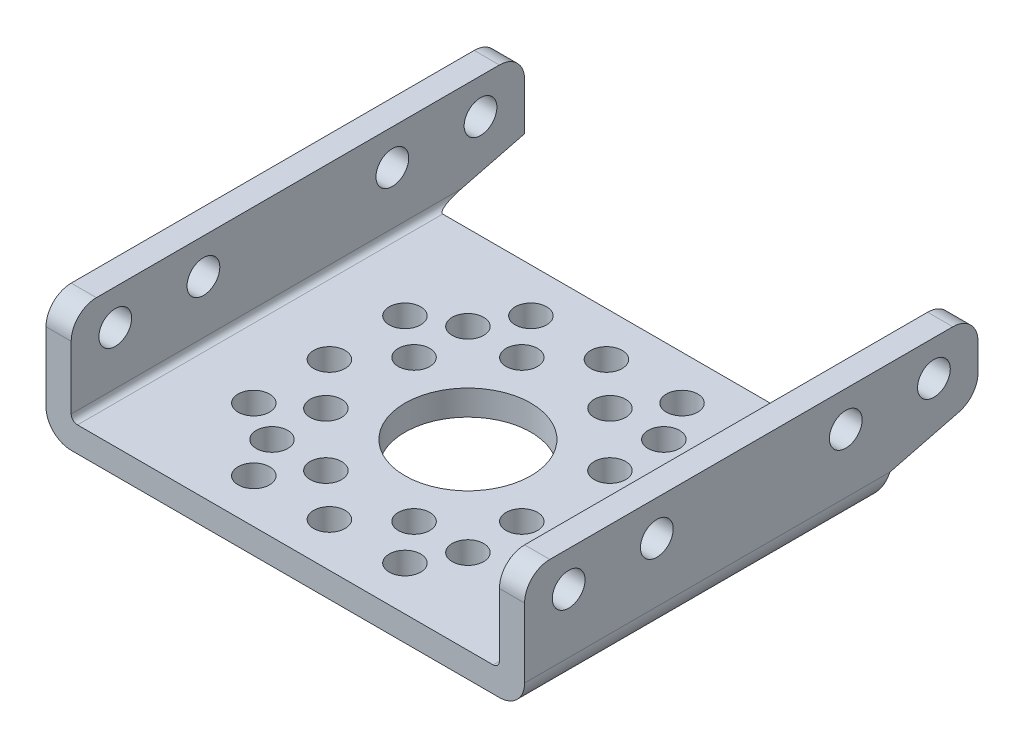
from build123d import *

# Parameters (mm, degrees)
SKETCH_1_W               = 38
SKETCH_1_H               = 29
EXTRUDE_1_DEPTH          = 2
SKETCH_2_W               = 2
SKETCH_2_H               = 36
EXTRUDE_2_DEPTH          = 7.5
SKETCH_3_R               = 5
SKETCH_3_R_2             = 1.25
CUT_EXTRUDE_1_DEPTH      = 8.5
CUT_EXTRUDE_1_DEPTH_BACK = 3
SKETCH_4_R               = 1.3
CUT_EXTRUDE_2_DEPTH      = 39
CUT_EXTRUDE_3_DEPTH      = 39
FILLET_1_R               = 2
FILLET_3_R               = 0.5
FILLET_4_R               = 2


with BuildPart() as part:
    # 스케치1 → 보스-돌출1 (new body)
    with BuildSketch(Plane(origin=(0, 0, 0), x_dir=(1, 0, 0), z_dir=(0, 1, 0))):
        with Locations((19, 14.5)):
            Rectangle(SKETCH_1_W, SKETCH_1_H)
    extrude(amount=EXTRUDE_1_DEPTH)

    # 스케치2 → 보스-돌출2 (add)
    with BuildSketch(Plane(origin=(0, 2, 0), x_dir=(1, 0, 0), z_dir=(0, 1, 0))):
        with Locations((1, 18)):
            Rectangle(SKETCH_2_W, SKETCH_2_H)
        with Locations((37, 18)):
            Rectangle(SKETCH_2_W, SKETCH_2_H)
    extrude(amount=EXTRUDE_2_DEPTH)

    # 스케치3 → 컷-돌출1 (cut, two sides)
    with BuildSketch(Plane(origin=(0, 2, 0), x_dir=(1, 0, 0), z_dir=(0, 1, 0))) as cut_extrude_1_sk:
        with Locations((19, 14.5)):
            Circle(SKETCH_3_R)
        with Locations((19, 25.5)):
            Circle(SKETCH_3_R_2)
        with Locations((26.778174593, 22.278174593)):
            Circle(SKETCH_3_R_2)
        with Locations((30, 14.5)):
            Circle(SKETCH_3_R_2)
        with Locations((26.778174593, 6.721825407)):
            Circle(SKETCH_3_R_2)
        with Locations((19, 3.5)):
            Circle(SKETCH_3_R_2)
        with Locations((11.221825407, 6.721825407)):
            Circle(SKETCH_3_R_2)
        with Locations((8, 14.5)):
            Circle(SKETCH_3_R_2)
        with Locations((11.221825407, 22.278174593)):
            Circle(SKETCH_3_R_2)
        with Locations((13, 25.5)):
            Circle(SKETCH_3_R_2)
        with Locations((25, 25.5)):
            Circle(SKETCH_3_R_2)
        with Locations((30, 20.5)):
            Circle(SKETCH_3_R_2)
        with Locations((30, 8.5)):
            Circle(SKETCH_3_R_2)
        with Locations((25, 3.5)):
            Circle(SKETCH_3_R_2)
        with Locations((13, 3.5)):
            Circle(SKETCH_3_R_2)
        with Locations((8, 8.5)):
            Circle(SKETCH_3_R_2)
        with Locations((8, 20.5)):
            Circle(SKETCH_3_R_2)
        with Locations((15.5, 22.278174593)):
            Circle(SKETCH_3_R_2)
        with Locations((22.5, 22.278174593)):
            Circle(SKETCH_3_R_2)
        with Locations((26.778174593, 18)):
            Circle(SKETCH_3_R_2)
        with Locations((26.778174593, 11)):
            Circle(SKETCH_3_R_2)
        with Locations((22.5, 6.721825407)):
            Circle(SKETCH_3_R_2)
        with Locations((15.5, 6.721825407)):
            Circle(SKETCH_3_R_2)
        with Locations((11.221825407, 11)):
            Circle(SKETCH_3_R_2)
        with Locations((11.221825407, 18)):
            Circle(SKETCH_3_R_2)
    extrude(amount=CUT_EXTRUDE_1_DEPTH, mode=Mode.SUBTRACT)
    extrude(cut_extrude_1_sk.sketch, amount=-CUT_EXTRUDE_1_DEPTH_BACK, mode=Mode.SUBTRACT)

    # 스케치4 → 컷-돌출2 (cut, through all)
    with BuildSketch(Plane(origin=(38, 0, 0), x_dir=(0, 0, -1), z_dir=(1, 0, 0))):
        with Locations((3.5, 6.7)):
            Circle(SKETCH_4_R)
        with Locations((25.5, 6.7)):
            Circle(SKETCH_4_R)
        with Locations((10.5, 6.7)):
            Circle(SKETCH_4_R)
        with Locations((32.5, 6.7)):
            Circle(SKETCH_4_R)
    extrude(amount=-CUT_EXTRUDE_2_DEPTH, mode=Mode.SUBTRACT)

    # 스케치5 → 컷-돌출3 (cut, through all)
    with BuildSketch(Plane(origin=(38, 0, 0), x_dir=(0, 0, -1), z_dir=(1, 0, 0))):
        Polygon((36, 3.77094162), (29, 2), (36, 2), align=None)
        Polygon((29, 2), (28.116343093, 0), (29, 0), align=None)
    extrude(amount=-CUT_EXTRUDE_3_DEPTH, mode=Mode.SUBTRACT)

    # 필렛1
    fillet_1_edges = [part.edges().sort_by_distance(p)[0] for p in [
        (1, 9.5, -36),
        (1, 9.5, 0),
        (37, 3.77094162, -36),
        (37, 9.5, 0),
        (37, 9.5, -36),
    ]]
    fillet(fillet_1_edges, radius=FILLET_1_R)

    # 필렛3
    fillet_3_edges = [part.edges().sort_by_distance(p)[0] for p in [
        (2, 2, -14.5),
        (36, 2, -14.5),
    ]]
    fillet(fillet_3_edges, radius=FILLET_3_R)

    # 필렛4
    fillet_4_edges = [part.edges().sort_by_distance(p)[0] for p in [
        (0, 0, -14.058171546),
        (38, 0, -14.058171546),
    ]]
    fillet(fillet_4_edges, radius=FILLET_4_R)


solid = part.part
